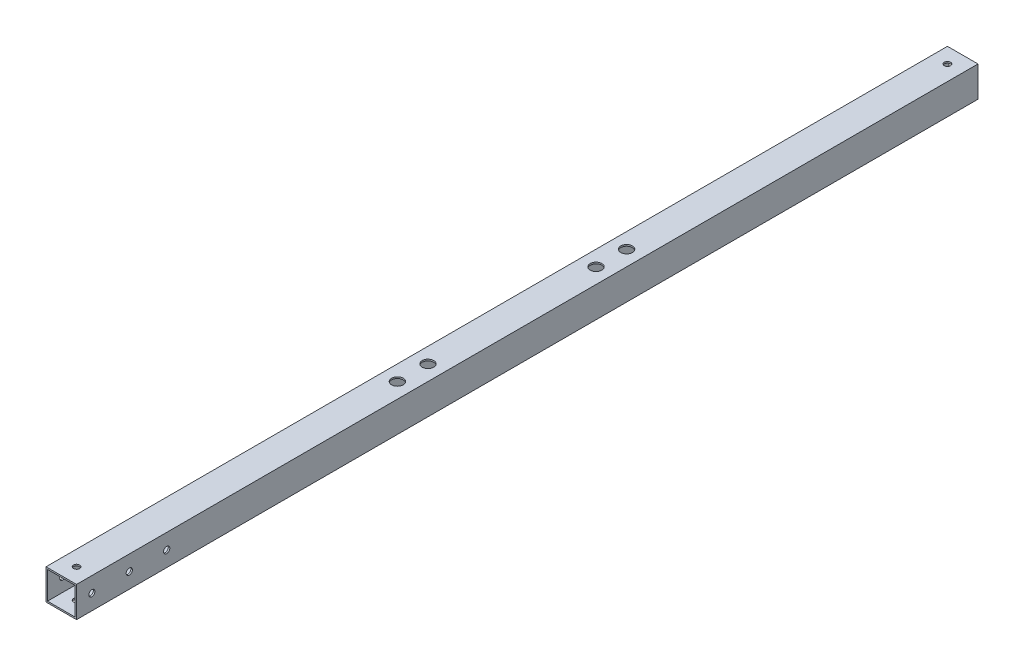
from build123d import *

# Parameters (mm, degrees)
SKETCH_1_W           = 20
SKETCH_1_H           = 20
SKETCH_1_W_2         = 18
SKETCH_1_H_2         = 18
EXTRUDE_1_DEPTH      = 295
SKETCH_2_R           = 2.025
CUT_EXTRUDE_1_DEPTH  = 45
SKETCH_3_R           = 3.8
CUT_EXTRUDE_2_DEPTH  = 5
SKETCH_4_R           = 2.025
CUT_EXTRUDE_3_DEPTH  = 73
SKETCH_15_R          = 2.025
CUT_EXTRUDE_14_DEPTH = 70


with BuildPart() as part:
    # 草图1 → 凸台-拉伸1 (new body, symmetric)
    with BuildSketch(Plane.XY):
        Rectangle(SKETCH_1_W, SKETCH_1_H)
        Rectangle(SKETCH_1_W_2, SKETCH_1_H_2, mode=Mode.SUBTRACT)
    extrude(amount=EXTRUDE_1_DEPTH, both=True)

    # 草图2 → 切除-拉伸1 (cut, symmetric)
    with BuildSketch(Plane(origin=(0, 10, 0), x_dir=(1, 0, 0), z_dir=(0, 1, 0))):
        with Locations((0, -75)):
            Circle(SKETCH_2_R)
        with Locations((0, -55)):
            Circle(SKETCH_2_R)
        with Locations((0, 55)):
            Circle(SKETCH_2_R)
        with Locations((0, 75)):
            Circle(SKETCH_2_R)
    extrude(amount=CUT_EXTRUDE_1_DEPTH, both=True, mode=Mode.SUBTRACT)

    # 草图3 → 切除-拉伸2 (cut, symmetric)
    with BuildSketch(Plane(origin=(0, 10, 0), x_dir=(1, 0, 0), z_dir=(0, 1, 0))):
        with Locations((0, 75)):
            Circle(SKETCH_3_R)
        with Locations((0, 55)):
            Circle(SKETCH_3_R)
        with Locations((0, -55)):
            Circle(SKETCH_3_R)
        with Locations((0, -75)):
            Circle(SKETCH_3_R)
    extrude(amount=CUT_EXTRUDE_2_DEPTH, both=True, mode=Mode.SUBTRACT)

    # 草图4 → 切除-拉伸3 (cut)
    with BuildSketch(Plane(origin=(10, 0, 0), x_dir=(0, 0, -1), z_dir=(1, 0, 0))):
        with Locations((-236, 0)):
            Circle(SKETCH_4_R)
        with Locations((-260.5, 0)):
            Circle(SKETCH_4_R)
        with Locations((-285, 0)):
            Circle(SKETCH_4_R)
    extrude(amount=-CUT_EXTRUDE_3_DEPTH, mode=Mode.SUBTRACT)

    # 草图15 → 切除-拉伸14 (cut)
    with BuildSketch(Plane.XZ.offset(10)):
        with Locations((0, 285)):
            Circle(SKETCH_15_R)
    cut_extrude_14 = extrude(amount=-CUT_EXTRUDE_14_DEPTH, mode=Mode.SUBTRACT)

    # 镜向2: 切除-拉伸14 across plane
    add(cut_extrude_14.mirror(Plane.XY), mode=Mode.SUBTRACT)


solid = part.part
